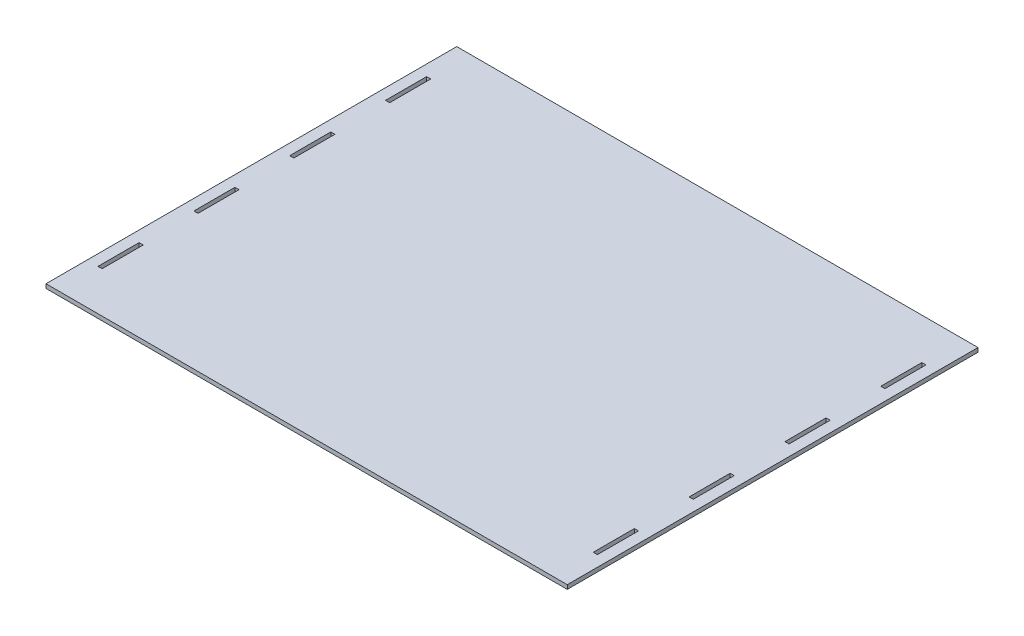
from build123d import *

# Parameters (mm, degrees)
SKETCH1_W           = 380.715714286
SKETCH1_H           = 300
SKETCH1_W_2         = 3
SKETCH1_H_2         = 30
BOSS_EXTRUDE1_DEPTH = 3


with BuildPart() as part:
    # Sketch1 → Boss-Extrude1 (new body)
    with BuildSketch(Plane(origin=(0, 0, 0), x_dir=(1, 0, 0), z_dir=(0, 1, 0))):
        with Locations((190.357857143, 150)):
            Rectangle(SKETCH1_W, SKETCH1_H)
        with Locations((9.495714286, 255)):
            Rectangle(SKETCH1_W_2, SKETCH1_H_2, mode=Mode.SUBTRACT)
        with Locations((9.495714286, 185)):
            Rectangle(SKETCH1_W_2, SKETCH1_H_2, mode=Mode.SUBTRACT)
        with Locations((9.495714286, 115)):
            Rectangle(SKETCH1_W_2, SKETCH1_H_2, mode=Mode.SUBTRACT)
        with Locations((9.495714286, 45)):
            Rectangle(SKETCH1_W_2, SKETCH1_H_2, mode=Mode.SUBTRACT)
        with Locations((371.215714286, 45)):
            Rectangle(SKETCH1_W_2, SKETCH1_H_2, mode=Mode.SUBTRACT)
        with Locations((371.215714286, 115)):
            Rectangle(SKETCH1_W_2, SKETCH1_H_2, mode=Mode.SUBTRACT)
        with Locations((371.215714286, 185)):
            Rectangle(SKETCH1_W_2, SKETCH1_H_2, mode=Mode.SUBTRACT)
        with Locations((371.215714286, 255)):
            Rectangle(SKETCH1_W_2, SKETCH1_H_2, mode=Mode.SUBTRACT)
    extrude(amount=BOSS_EXTRUDE1_DEPTH)


solid = part.part
